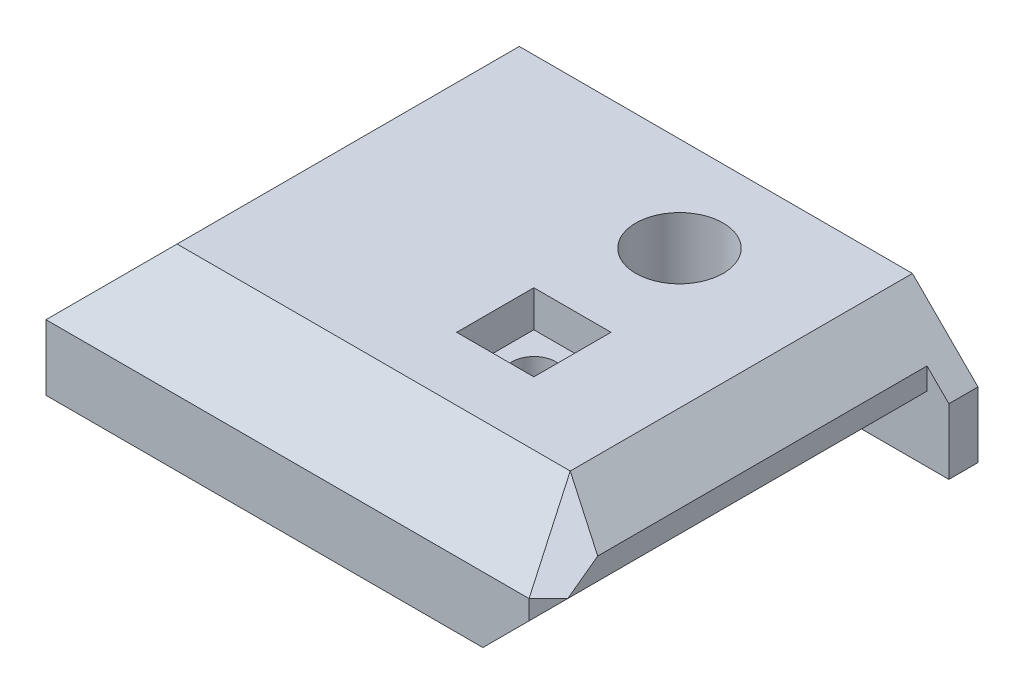
from build123d import *

# Parameters (mm, degrees)
SKETCH1_W               = 36
SKETCH1_H               = 9
BOSS_EXTRUDE1_DEPTH     = 28
CUT_EXTRUDE1_DEPTH      = 28
CUT_EXTRUDE2_DEPTH      = 36
SKETCH5_W               = 11.440376565
SKETCH5_H               = 15.618965423
CUT_EXTRUDE4_DEPTH      = 2
CUT_EXTRUDE5_DEPTH      = 2
CUT_EXTRUDE5_DEPTH_BACK = 2
CUT_EXTRUDE6_DEPTH      = 26
CUT_EXTRUDE7_DEPTH      = 26
SKETCH10_R              = 3
CUT_EXTRUDE8_DEPTH      = 7
SKETCH11_R              = 1.5
CUT_EXTRUDE9_DEPTH      = 2
SKETCH12_R              = 1.5
CUT_EXTRUDE10_DEPTH     = 9
SKETCH13_W              = 5.3
SKETCH13_H              = 5.3
CUT_EXTRUDE11_DEPTH     = 2.5


with BuildPart() as part:
    # Sketch1 → Boss-Extrude1 (new body)
    with BuildSketch(Plane.XY):
        with Locations((18, 4.5)):
            Rectangle(SKETCH1_W, SKETCH1_H)
    extrude(amount=BOSS_EXTRUDE1_DEPTH)

    # Sketch2 → Cut-Extrude1 (cut)
    with BuildSketch(Plane.XY):
        Polygon((0, 4.5), (4.5, 9), (0, 9), align=None)
        Polygon((36, 4.5), (31.5, 9), (36, 9), align=None)
    extrude(amount=CUT_EXTRUDE1_DEPTH, mode=Mode.SUBTRACT)

    # Sketch3 → Cut-Extrude2 (cut)
    with BuildSketch(Plane(origin=(0, 0, 0), x_dir=(0, 0, -1), z_dir=(1, 0, 0))):
        Polygon((-28, 4.5), (-23.5, 9), (-28, 9), align=None)
    extrude(amount=CUT_EXTRUDE2_DEPTH, mode=Mode.SUBTRACT)

    # Sketch5 → Cut-Extrude4 (cut)
    with BuildSketch(Plane(origin=(32, 0, 32), x_dir=(0, 1, 0), z_dir=(0.707106781, 0, 0.707106781))):
        with Locations((5.720188283, -5.935696583)):
            Rectangle(SKETCH5_W, SKETCH5_H)
    extrude(amount=-CUT_EXTRUDE4_DEPTH, mode=Mode.SUBTRACT)

    # Sketch6 → Cut-Extrude5 (cut, two sides)
    with BuildSketch(Plane(origin=(4, 0, -4), x_dir=(0.577350269, -0.577350269, 0.577350269), z_dir=(-0.707106781, 0, 0.707106781))) as cut_extrude5_sk:
        Polygon((26.558112383, 29.802125204), (32.719347855, 28.647424665), (30.19862658, 32.212262879), align=None)
    extrude(amount=CUT_EXTRUDE5_DEPTH, mode=Mode.SUBTRACT)
    extrude(cut_extrude5_sk.sketch, amount=-CUT_EXTRUDE5_DEPTH_BACK, mode=Mode.SUBTRACT)

    # Sketch7 → Cut-Extrude6 (cut)
    with BuildSketch(Plane.XY):
        Polygon((5, 0), (5, 3), (5.707106781, 3.707106781), (13.104524105, 3.707106781), (13.811630886, 3), (13.811630886, 0), align=None)
    extrude(amount=CUT_EXTRUDE6_DEPTH, mode=Mode.SUBTRACT)

    # Sketch8 → Cut-Extrude7 (cut)
    with BuildSketch(Plane.XY.offset(28)):
        Polygon((36, 0), (30, 0), (34.5, 4.5), (34.5, 6), (36, 6), align=None)
    extrude(amount=-CUT_EXTRUDE7_DEPTH, mode=Mode.SUBTRACT)

    # Sketch10 → Cut-Extrude8 (cut)
    with BuildSketch(Plane(origin=(0, 9, 0), x_dir=(1, 0, 0), z_dir=(0, 1, 0))):
        with Locations((22, -6.5)):
            Circle(SKETCH10_R)
    extrude(amount=-CUT_EXTRUDE8_DEPTH, mode=Mode.SUBTRACT)

    # Sketch11 → Cut-Extrude9 (cut)
    with BuildSketch(Plane(origin=(0, 2, 0), x_dir=(1, 0, 0), z_dir=(0, 1, 0))):
        with Locations((22, -6.5)):
            Circle(SKETCH11_R)
    extrude(amount=-CUT_EXTRUDE9_DEPTH, mode=Mode.SUBTRACT)

    # Sketch12 → Cut-Extrude10 (cut)
    with BuildSketch(Plane(origin=(0, 0, 0), x_dir=(1, 0, 0), z_dir=(0, 1, 0))):
        with Locations((22, -16.5)):
            Circle(SKETCH12_R)
    extrude(amount=CUT_EXTRUDE10_DEPTH, mode=Mode.SUBTRACT)

    # Sketch13 → Cut-Extrude11 (cut)
    with BuildSketch(Plane(origin=(0, 9, 0), x_dir=(1, 0, 0), z_dir=(0, 1, 0))):
        with Locations((22, -16.5)):
            Rectangle(SKETCH13_W, SKETCH13_H)
    extrude(amount=-CUT_EXTRUDE11_DEPTH, mode=Mode.SUBTRACT)


solid = part.part
